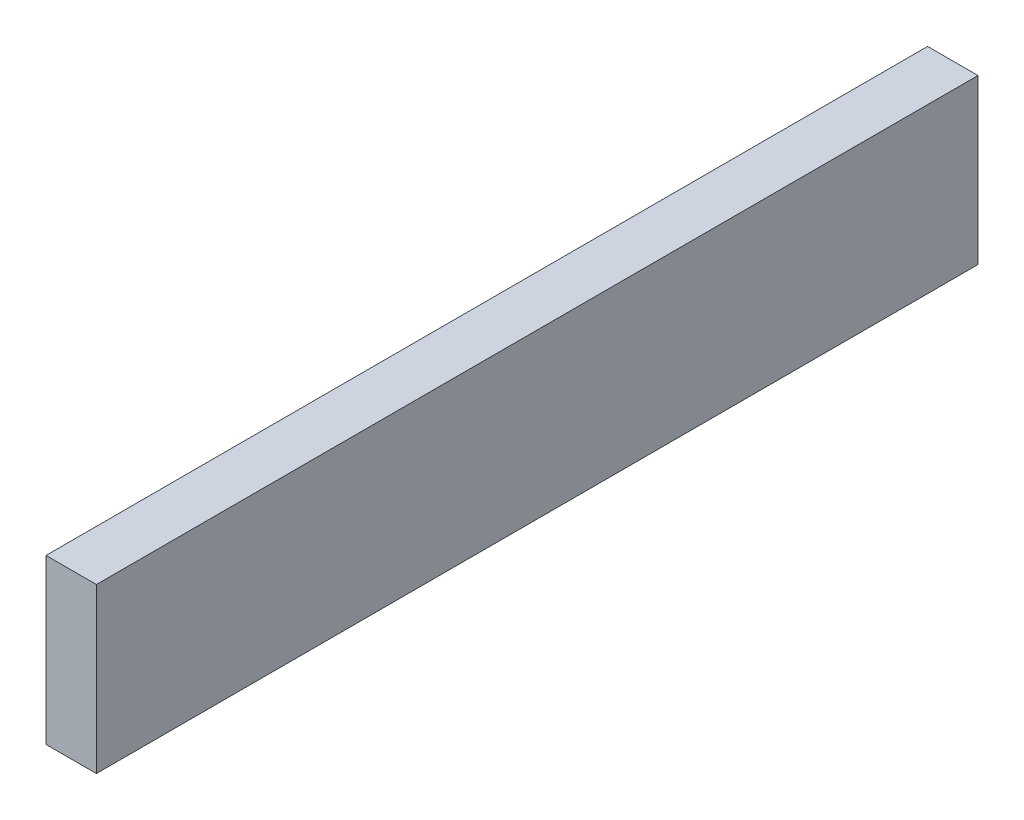
from build123d import *

# Parameters (mm, degrees)
SKETCH1_W           = 4
SKETCH1_H           = 13
BOSS_EXTRUDE1_DEPTH = 70


with BuildPart() as part:
    # Sketch1 → Boss-Extrude1 (new body)
    with BuildSketch(Plane.XY):
        with Locations((2, 6.5)):
            Rectangle(SKETCH1_W, SKETCH1_H)
    extrude(amount=BOSS_EXTRUDE1_DEPTH)


solid = part.part
